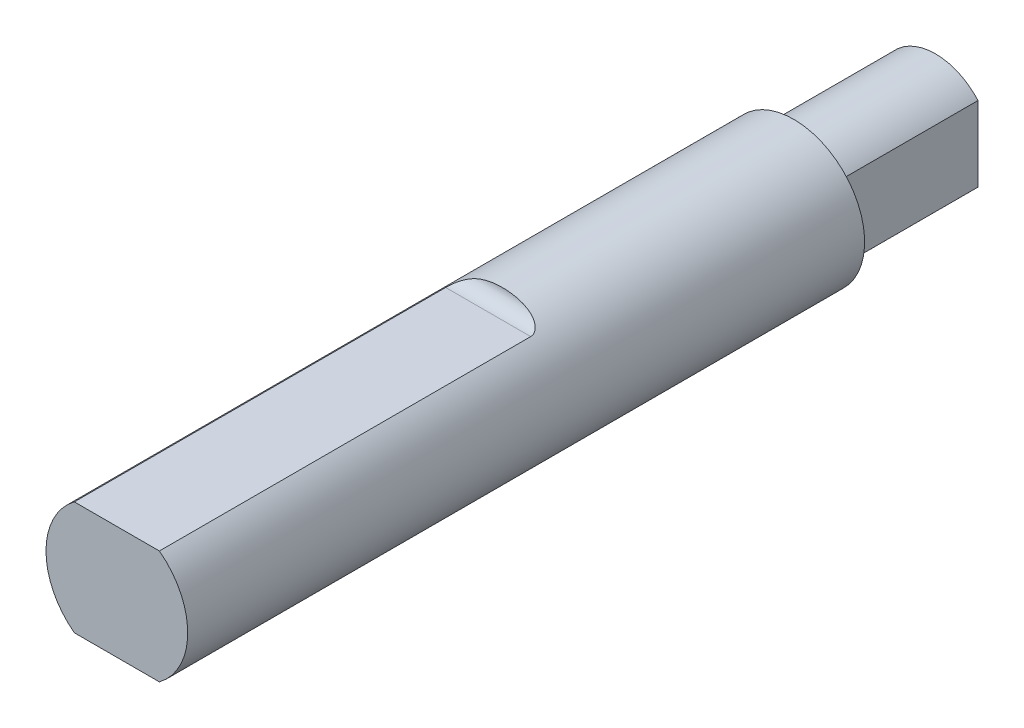
from build123d import *

# Parameters (mm, degrees)
SKETCH1_R               = 2.5
BOSS_EXTRUDE1_DEPTH     = 28.879
SKETCH2_R               = 2.5
CUT_EXTRUDE1_DEPTH      = 5
CUT_EXTRUDE2_DEPTH      = 13.1
CUT_EXTRUDE3_DEPTH      = 3.5
CUT_EXTRUDE3_DEPTH_BACK = 3.5


with BuildPart() as part:
    # Sketch1 → Boss-Extrude1 (new body)
    with BuildSketch(Plane.XY):
        Circle(SKETCH1_R)
    extrude(amount=BOSS_EXTRUDE1_DEPTH)

    # Sketch2 → Cut-Extrude1 (cut)
    with BuildSketch(Plane(origin=(0, 0, 0), x_dir=(-1, 0, 0), z_dir=(0, 0, -1))):
        Circle(SKETCH2_R)
        with BuildLine():
            Line((-1.5, 1.322875656), (-1.5, -1.322875656))
            ThreePointArc((-1.5, -1.322875656), (0, -2), (1.5, -1.322875656))
            Line((1.5, -1.322875656), (1.5, 1.322875656))
            ThreePointArc((1.5, 1.322875656), (0, 2), (-1.5, 1.322875656))
        make_face(mode=Mode.SUBTRACT)
    extrude(amount=-CUT_EXTRUDE1_DEPTH, mode=Mode.SUBTRACT)

    # Sketch3 → Cut-Extrude2 (cut)
    with BuildSketch(Plane.XY.offset(28.879)):
        with BuildLine():
            Line((-1.5, 2), (1.5, 2))
            ThreePointArc((1.5, 2), (0, 2.5), (-1.5, 2))
        make_face()
        with BuildLine():
            Line((-1.5, -2), (1.5, -2))
            ThreePointArc((1.5, -2), (0, -2.5), (-1.5, -2))
        make_face()
    extrude(amount=-CUT_EXTRUDE2_DEPTH, mode=Mode.SUBTRACT)

    # Sketch4 → Cut-Extrude3 (cut, two sides)
    with BuildSketch(Plane(origin=(0, 0, 0), x_dir=(0, 0, -1), z_dir=(1, 0, 0))) as cut_extrude3_sk:
        with BuildLine():
            Line((-15.779, 2.5), (-15.779, 2))
            ThreePointArc((-15.779, 2), (-15.425446609, 2.146446609), (-15.279, 2.5))
            Line((-15.279, 2.5), (-15.779, 2.5))
        make_face()
        with BuildLine():
            Line((-15.779, -2.5), (-15.779, -2))
            ThreePointArc((-15.779, -2), (-15.425446609, -2.146446609), (-15.279, -2.5))
            Line((-15.279, -2.5), (-15.779, -2.5))
        make_face()
    extrude(amount=CUT_EXTRUDE3_DEPTH, mode=Mode.SUBTRACT)
    extrude(cut_extrude3_sk.sketch, amount=-CUT_EXTRUDE3_DEPTH_BACK, mode=Mode.SUBTRACT)


solid = part.part
